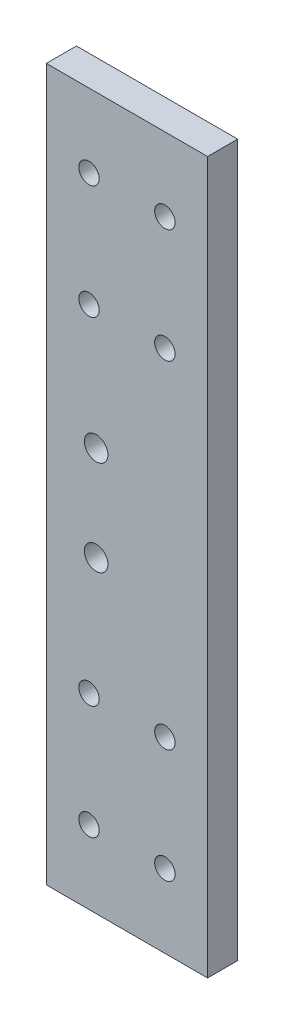
from build123d import *

# Parameters (mm, degrees)
SKETCH1_W              = 34
SKETCH1_H              = 150
BOSS_EXTRUDE1_DEPTH    = 6.35
F_8_CLEARANCE_HOLE1_D  = 4.3053
F_10_CLEARANCE_HOLE1_D = 4.9784


with BuildPart() as part:
    # Sketch1 → Boss-Extrude1 (new body)
    with BuildSketch(Plane.XY):
        Rectangle(SKETCH1_W, SKETCH1_H)
    extrude(amount=BOSS_EXTRUDE1_DEPTH)

    # #8 Clearance Hole1 (through all)
    with Locations(Plane.XY.offset(6.35)):
        with Locations((-8, 59.5), (8, 59.5), (8, 35.5), (-8, 35.5), (-8, -35.5), (-8, -59.5), (8, -59.5), (8, -35.5)):
            Hole(F_8_CLEARANCE_HOLE1_D / 2)

    # #10 Clearance Hole1 (through all)
    with Locations(Plane.XY.offset(6.35)):
        with Locations((-6.5, 10), (-6.5, -10)):
            Hole(F_10_CLEARANCE_HOLE1_D / 2)


solid = part.part
